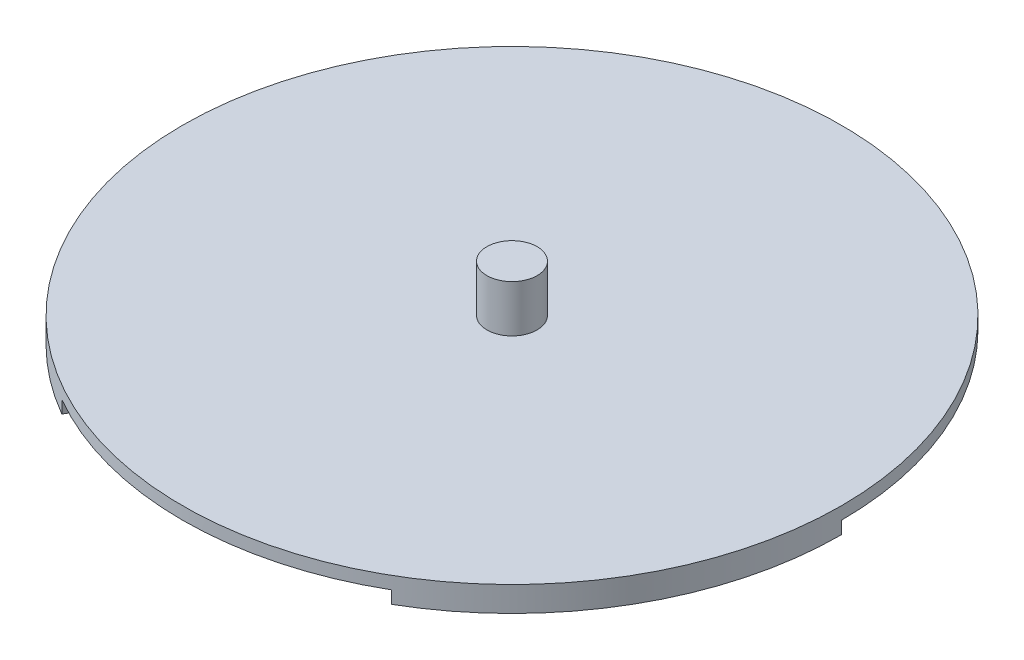
from build123d import *

# Parameters (mm, degrees)
SKETCH1_W           = 105
SKETCH1_H           = 8
CUT_EXTRUDE1_DEPTH  = 4
BOSS_EXTRUDE1_DEPTH = 4
BOSS_EXTRUDE2_DEPTH = 4
SKETCH5_W           = 8
SKETCH5_H           = 15


with BuildPart() as part:
    # Sketch1 → Revolve1 (revolve)
    with BuildSketch(Plane.XY):
        with Locations((52.5, 4)):
            Rectangle(SKETCH1_W, SKETCH1_H)
    revolve(axis=Axis((0, 8, 0), (0, -1, 0)))

    # Sketch2 → Cut-Extrude1 (cut)
    with BuildSketch(Plane.XZ):
        with BuildLine():
            Line((46.25, 80.10734985), (52.5, 90.932667397))
            ThreePointArc((52.5, 90.932667397), (-90.932667397, -52.5), (105, 0))
            Line((105, 0), (92.5, 0))
            ThreePointArc((92.5, 0), (80.10734985, 46.25), (46.25, 80.10734985))
        make_face()
    extrude(amount=-CUT_EXTRUDE1_DEPTH, mode=Mode.SUBTRACT)

    # Sketch3 → Boss-Extrude1 (add)
    with BuildSketch(Plane.XZ.offset(-4)):
        with BuildLine():
            Line((-92.5, 0), (-105, 0))
            ThreePointArc((-105, 0), (-90.932667397, 52.5), (-52.5, 90.932667397))
            Line((-52.5, 90.932667397), (-46.25, 80.10734985))
            ThreePointArc((-46.25, 80.10734985), (-80.10734985, 46.25), (-92.5, 0))
        make_face()
    extrude(amount=BOSS_EXTRUDE1_DEPTH)

    # Sketch4 → Boss-Extrude2 (add)
    with BuildSketch(Plane.XZ.offset(-4)):
        with BuildLine():
            Line((-52.5, -90.932667397), (-46.25, -80.10734985))
            ThreePointArc((-46.25, -80.10734985), (0, -92.5), (46.25, -80.10734985))
            Line((46.25, -80.10734985), (52.5, -90.932667397))
            ThreePointArc((52.5, -90.932667397), (0, -105), (-52.5, -90.932667397))
        make_face()
    extrude(amount=BOSS_EXTRUDE2_DEPTH)

    # Sketch5 → Revolve2 (revolve)
    with BuildSketch(Plane.XY):
        with Locations((4, 15.5)):
            Rectangle(SKETCH5_W, SKETCH5_H)
    revolve(axis=Axis((0, 23, 0), (0, -1, 0)))


solid = part.part
